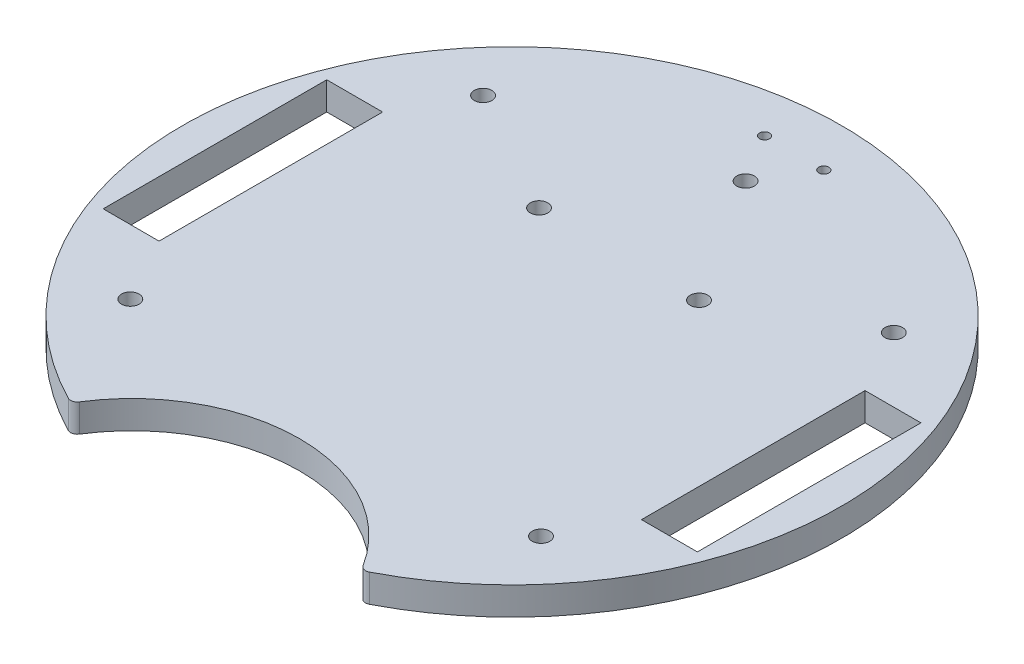
from build123d import *

# Parameters (mm, degrees)
SKETCH1_R           = 2
SKETCH1_R_2         = 1.143
SKETCH1_W           = 12.7
SKETCH1_H           = 50.8
BOSS_EXTRUDE3_DEPTH = 6.35


with BuildPart() as part:
    # Sketch1 → Boss-Extrude3 (new body)
    with BuildSketch(Plane(origin=(0, 0, 0), x_dir=(1, 0, 0), z_dir=(0, 1, 0))):
        with BuildLine():
            ThreePointArc((32.240681933, -66.10056535), (0, -48.302004425), (-32.240681933, -66.10056535))
            ThreePointArc((-32.240681933, -66.10056535), (-33.11372382, -66.748004461), (-34.194833578, -66.63583839))
            ThreePointArc((-34.194833578, -66.63583839), (0, 74.897407173), (34.194833578, -66.63583839))
            ThreePointArc((34.194833578, -66.63583839), (33.11372382, -66.748004461), (32.240681933, -66.10056535))
        make_face()
        with Locations((-18.178952795, 24.310551096)):
            Circle(SKETCH1_R, mode=Mode.SUBTRACT)
        with Locations((-46.663733983, -40.081231883)):
            Circle(SKETCH1_R, mode=Mode.SUBTRACT)
        with Locations((46.663733983, -40.081231883)):
            Circle(SKETCH1_R, mode=Mode.SUBTRACT)
        with Locations((46.663733983, 40.081231883)):
            Circle(SKETCH1_R, mode=Mode.SUBTRACT)
        with Locations((-46.663733983, 40.081231883)):
            Circle(SKETCH1_R, mode=Mode.SUBTRACT)
        with Locations((-6.731, 64.107698843)):
            Circle(SKETCH1_R_2, mode=Mode.SUBTRACT)
        with Locations((6.731, 64.107698843)):
            Circle(SKETCH1_R_2, mode=Mode.SUBTRACT)
        with Locations((18.178952795, 24.310551096)):
            Circle(SKETCH1_R, mode=Mode.SUBTRACT)
        with Locations((0, 53.061187965)):
            Circle(SKETCH1_R, mode=Mode.SUBTRACT)
        with Locations((61.164123727, 0)):
            Rectangle(SKETCH1_W, SKETCH1_H, mode=Mode.SUBTRACT)
        with Locations((-61.164123727, 0)):
            Rectangle(SKETCH1_W, SKETCH1_H, mode=Mode.SUBTRACT)
    extrude(amount=BOSS_EXTRUDE3_DEPTH)


solid = part.part
